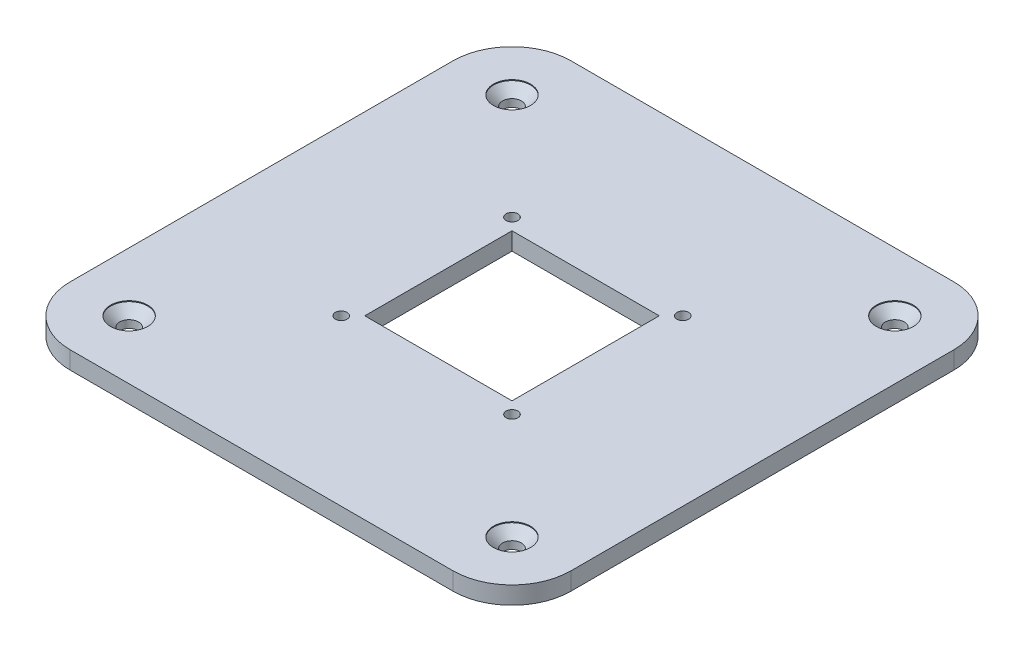
from build123d import *

# Parameters (mm, degrees)
SKETCH1_W                                      = 85
SKETCH1_H                                      = 85
BOSS_EXTRUDE1_DEPTH                            = 3
FILLET1_R                                      = 10
CUT_EXTRUDE1_REACH                             = 5
SKETCH3_W                                      = 25
SKETCH3_H                                      = 25
CSK_FOR_M3_FLAT_HEAD_MACHINE_SCREW1_AT_2_COUNT = 2
CSK_FOR_M3_FLAT_HEAD_MACHINE_SCREW1_AT_2_PITCH = 65
CSK_FOR_M3_FLAT_HEAD_MACHINE_SCREW1_AT_3_COUNT = 2
CSK_FOR_M3_FLAT_HEAD_MACHINE_SCREW1_AT_3_PITCH = 91.923881554
CSK_FOR_M3_FLAT_HEAD_MACHINE_SCREW1_AT_4_COUNT = 2
CSK_FOR_M3_FLAT_HEAD_MACHINE_SCREW1_AT_4_PITCH = 65
SKETCH6_R                                      = 1
CUT_EXTRUDE2_DEPTH                             = 4


with BuildPart() as part:
    # Sketch1 → Boss-Extrude1 (new body)
    with BuildSketch(Plane(origin=(0, 0, 0), x_dir=(1, 0, 0), z_dir=(0, 1, 0))):
        Rectangle(SKETCH1_W, SKETCH1_H)
    extrude(amount=BOSS_EXTRUDE1_DEPTH)

    # Fillet1
    fillet1_edges = [part.edges().sort_by_distance(p)[0] for p in [
        (42.5, 1.5, 42.5),
        (-42.5, 1.5, 42.5),
        (-42.5, 1.5, -42.5),
        (42.5, 1.5, -42.5),
    ]]
    fillet(fillet1_edges, radius=FILLET1_R)

    # Sketch3 → Cut-Extrude1 (cut, up to next)
    with BuildSketch(Plane(origin=(0, 3, 0), x_dir=(1, 0, 0), z_dir=(0, 1, 0)), mode=Mode.PRIVATE) as cut_extrude1_sk1:
        Rectangle(SKETCH3_W, SKETCH3_H)
    cut_extrude1_tool1 = extrude(cut_extrude1_sk1.sketch, amount=-CUT_EXTRUDE1_REACH, mode=Mode.PRIVATE) & part.part
    add(cut_extrude1_tool1.solids().sort_by_distance((0, 3, 0))[0], mode=Mode.SUBTRACT)

    # Sketch4 → CSK for M3 Flat Head Machine Screw1 (revolve, cut)
    with BuildSketch(Plane(origin=(32.5, 3, -32.5), x_dir=(0, 0, 1), z_dir=(1, 0, 0))):
        Polygon((0, 0), (0, 3), (1.6, 3), (1.6, 1.7), (3.15, 0.15), (3.15, 0), align=None)
    csk_for_m3_flat_head_machine_screw1 = revolve(axis=Axis((32.5, 9.35, -32.5), (0, -1, 0)), mode=Mode.SUBTRACT)

    # CSK for M3 Flat Head Machine Screw1 at 2: CSK for M3 Flat Head Machine Screw1 ×2
    with Locations(*[(0, 0, i * CSK_FOR_M3_FLAT_HEAD_MACHINE_SCREW1_AT_2_PITCH) for i in range(1, CSK_FOR_M3_FLAT_HEAD_MACHINE_SCREW1_AT_2_COUNT)]):
        add(csk_for_m3_flat_head_machine_screw1, mode=Mode.SUBTRACT)

    # CSK for M3 Flat Head Machine Screw1 at 3: CSK for M3 Flat Head Machine Screw1 ×2
    with Locations(*[Vector(-0.707106781, 0, 0.707106781) * (i * CSK_FOR_M3_FLAT_HEAD_MACHINE_SCREW1_AT_3_PITCH) for i in range(1, CSK_FOR_M3_FLAT_HEAD_MACHINE_SCREW1_AT_3_COUNT)]):
        add(csk_for_m3_flat_head_machine_screw1, mode=Mode.SUBTRACT)

    # CSK for M3 Flat Head Machine Screw1 at 4: CSK for M3 Flat Head Machine Screw1 ×2
    with Locations(*[(-i * CSK_FOR_M3_FLAT_HEAD_MACHINE_SCREW1_AT_4_PITCH, 0, 0) for i in range(1, CSK_FOR_M3_FLAT_HEAD_MACHINE_SCREW1_AT_4_COUNT)]):
        add(csk_for_m3_flat_head_machine_screw1, mode=Mode.SUBTRACT)

    # Sketch6 → Cut-Extrude2 (cut, through all)
    with BuildSketch(Plane(origin=(0, 3, 0), x_dir=(1, 0, 0), z_dir=(0, 1, 0))):
        with Locations((-14.5, 14.5)):
            Circle(SKETCH6_R)
        with Locations((14.5, 14.5)):
            Circle(SKETCH6_R)
        with Locations((14.5, -14.5)):
            Circle(SKETCH6_R)
        with Locations((-14.5, -14.5)):
            Circle(SKETCH6_R)
    extrude(amount=-CUT_EXTRUDE2_DEPTH, mode=Mode.SUBTRACT)


solid = part.part
